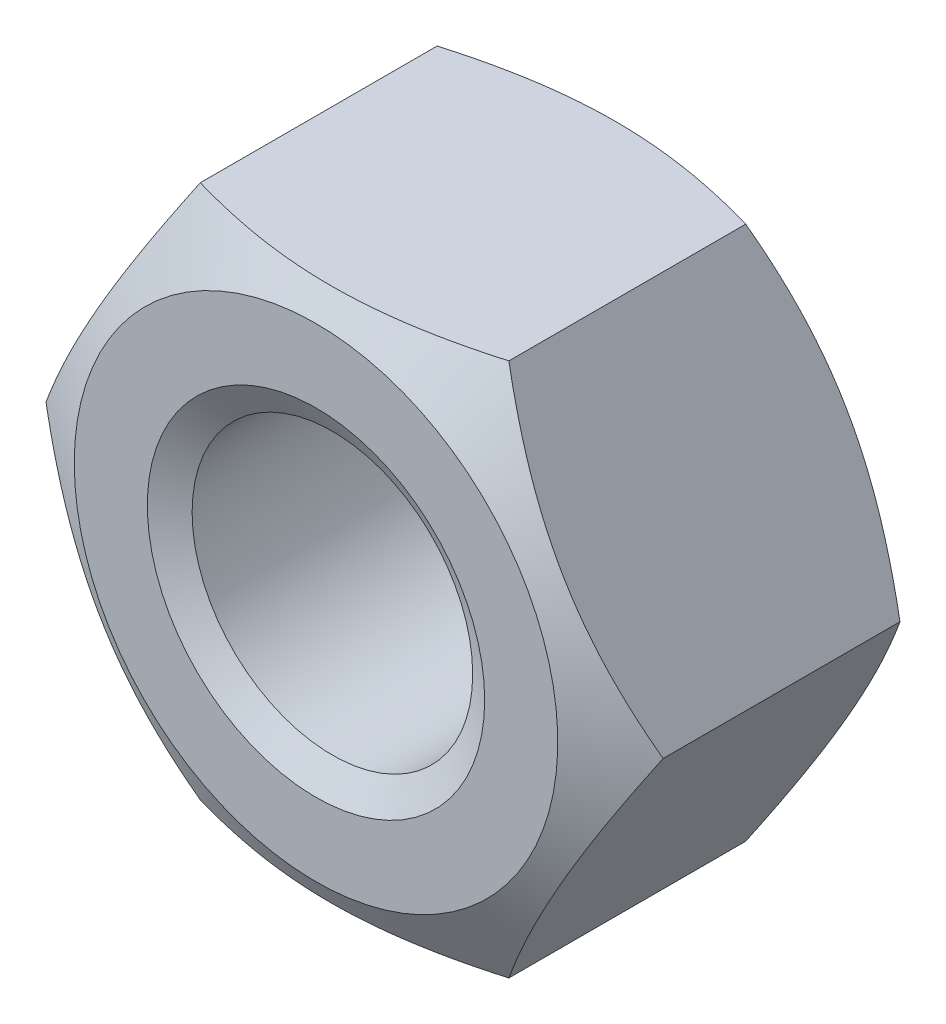
from build123d import *

# Parameters (mm, degrees)
EXTRUDE_1_DEPTH = 4.7


with BuildPart() as part:
    # 草图1 → 凸台-拉伸1 (new body)
    with BuildSketch(Plane.XY):
        Polygon((2.309401077, 4), (-2.309401077, 4), (-4.618802154, 0), (-2.309401077, -4), (2.309401077, -4), (4.618802154, 0), align=None)
    extrude(amount=EXTRUDE_1_DEPTH)

    # 草图2 → M5 螺纹孔1 (revolve, cut)
    with BuildSketch(Plane(origin=(0, 0, 4.7), x_dir=(0, -1, 0), z_dir=(1, 0, 0))):
        Polygon((0, 0), (0, 4.7), (2.525, 4.7), (2.1, 4.454626136), (2.1, 0.245373864), (2.525, 0), align=None)
    revolve(axis=Axis((0, 0, 11.05), (0, 0, -1)), mode=Mode.SUBTRACT)

    # 草图4 → 切除-旋转1 (revolve, cut)
    with BuildSketch(Plane(origin=(0, 0, 0), x_dir=(1, 0, 0), z_dir=(0, 1, 0))):
        Polygon((-4.618802154, -0.577350269), (-3.618802154, 0), (-4.618802154, 0), align=None)
        Polygon((-4.618802154, -4.7), (-3.618802154, -4.7), (-4.618802154, -4.122649731), align=None)
    revolve(axis=Axis((0, 0, 0), (0, 0, 1)), mode=Mode.SUBTRACT)


solid = part.part
